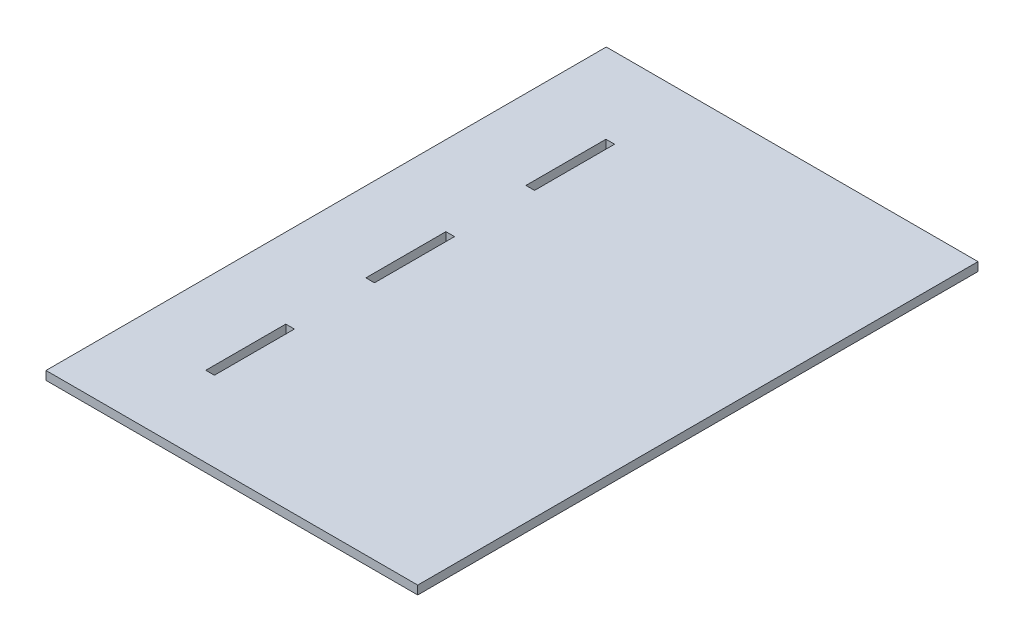
from build123d import *

# Parameters (mm, degrees)
SKETCH1_W           = 10.16
SKETCH1_H           = 94.342857143
BOSS_EXTRUDE1_DEPTH = 10.16


with BuildPart() as part:
    # Sketch1 → Boss-Extrude1 (new body)
    with BuildSketch(Plane(origin=(0, 0, 0), x_dir=(1, 0, 0), z_dir=(0, 1, 0))):
        Polygon((93.98, 0), (0, 0), (0, -660.4), (93.98, -660.4), (93.98, -566.057142857), (93.98, -471.714285714), (93.98, -377.371428571), (93.98, -283.028571429), (93.98, -188.685714286), (93.98, -94.342857143), align=None)
        Polygon((438.15, 0), (104.14, 0), (104.14, -94.342857143), (104.14, -188.685714286), (104.14, -283.028571429), (104.14, -377.371428571), (104.14, -471.714285714), (104.14, -566.057142857), (104.14, -660.4), (438.15, -660.4), align=None)
        with Locations((99.06, -47.171428572)):
            Rectangle(SKETCH1_W, SKETCH1_H)
        with Locations((99.06, -235.857142858)):
            Rectangle(SKETCH1_W, SKETCH1_H)
        with Locations((99.06, -424.542857142)):
            Rectangle(SKETCH1_W, SKETCH1_H)
        with Locations((99.06, -613.228571429)):
            Rectangle(SKETCH1_W, SKETCH1_H)
    extrude(amount=BOSS_EXTRUDE1_DEPTH)


solid = part.part
